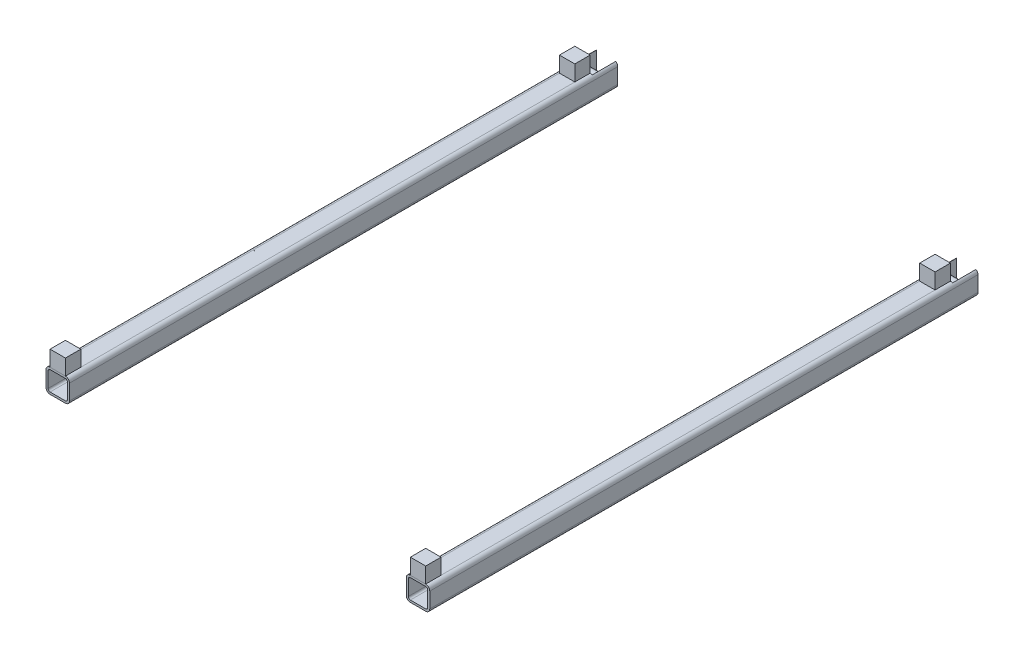
from build123d import *

# Parameters (mm, degrees)
SQUARE_TUBE_CONFIGURED_30_X_30_X_2_6_4_DEPTH = 700
SQUARE_TUBE_CONFIGURED_30_X_30_X_2_2_DEPTH   = 700
SKETCH113_W                                  = 24.8
SKETCH113_H                                  = 30
CUT_EXTRUDE1_DEPTH                           = 429.281449517
BOSS_EXTRUDE1_REACH                          = 582.279
SKETCH114_R                                  = 5
SKETCH115_W                                  = 24.8
SKETCH115_H                                  = 30
CUT_EXTRUDE2_DEPTH                           = 429.281449517
SKETCH117_W                                  = 19.6
SKETCH117_H                                  = 19.6
BOSS_EXTRUDE2_DEPTH                          = 20
SKETCH118_W                                  = 19.6
SKETCH118_H                                  = 19.6
BOSS_EXTRUDE3_DEPTH                          = 20


with BuildPart() as part:
    # Sketch116 → Square tube - configured 30 X 30 X 2.6(4) (new body)
    with BuildSketch(Plane(origin=(-230, 0, -350), x_dir=(0, 1, 0), z_dir=(0, 0, 1))):
        with BuildLine():
            Line((-9.8, -15), (9.8, -15))
            ThreePointArc((9.8, -15), (13.476955262, -13.476955262), (15, -9.8))
            Line((15, -9.8), (15, 9.8))
            ThreePointArc((15, 9.8), (13.476955262, 13.476955262), (9.8, 15))
            Line((9.8, 15), (-9.8, 15))
            ThreePointArc((-9.8, 15), (-13.476955262, 13.476955262), (-15, 9.8))
            Line((-15, 9.8), (-15, -9.8))
            ThreePointArc((-15, -9.8), (-13.476955262, -13.476955262), (-9.8, -15))
        make_face()
        with BuildLine():
            Line((-9.8, -12.4), (9.8, -12.4))
            ThreePointArc((9.8, -12.4), (11.638477631, -11.638477631), (12.4, -9.8))
            Line((12.4, -9.8), (12.4, 9.8))
            ThreePointArc((12.4, 9.8), (11.638477631, 11.638477631), (9.8, 12.4))
            Line((9.8, 12.4), (-9.8, 12.4))
            ThreePointArc((-9.8, 12.4), (-11.638477631, 11.638477631), (-12.4, 9.8))
            Line((-12.4, 9.8), (-12.4, -9.8))
            ThreePointArc((-12.4, -9.8), (-11.638477631, -11.638477631), (-9.8, -12.4))
        make_face(mode=Mode.SUBTRACT)
    extrude(amount=SQUARE_TUBE_CONFIGURED_30_X_30_X_2_6_4_DEPTH)

    # Sketch113 → Cut-Extrude1 (cut, through all)
    with BuildSketch(Plane(origin=(0, 15, 0), x_dir=(1, 0, 0), z_dir=(0, 1, 0))):
        with Locations((-230, 335)):
            Rectangle(SKETCH113_W, SKETCH113_H)
    extrude(amount=-CUT_EXTRUDE1_DEPTH, mode=Mode.SUBTRACT)


with BuildPart() as body_2:
    # Sketch116 on segment 2 (carried to segment 2) → Square tube - configured 30 X 30 X 2 2 (new body)
    with BuildSketch(Plane(origin=(230, 0, -350), x_dir=(0, 1, 0), z_dir=(0, 0, 1))):
        with BuildLine():
            Line((-9.8, -15), (9.8, -15))
            ThreePointArc((9.8, -15), (13.476955262, -13.476955262), (15, -9.8))
            Line((15, -9.8), (15, 9.8))
            ThreePointArc((15, 9.8), (13.476955262, 13.476955262), (9.8, 15))
            Line((9.8, 15), (-9.8, 15))
            ThreePointArc((-9.8, 15), (-13.476955262, 13.476955262), (-15, 9.8))
            Line((-15, 9.8), (-15, -9.8))
            ThreePointArc((-15, -9.8), (-13.476955262, -13.476955262), (-9.8, -15))
        make_face()
        with BuildLine():
            Line((-9.8, -12.4), (9.8, -12.4))
            ThreePointArc((9.8, -12.4), (11.638477631, -11.638477631), (12.4, -9.8))
            Line((12.4, -9.8), (12.4, 9.8))
            ThreePointArc((12.4, 9.8), (11.638477631, 11.638477631), (9.8, 12.4))
            Line((9.8, 12.4), (-9.8, 12.4))
            ThreePointArc((-9.8, 12.4), (-11.638477631, 11.638477631), (-12.4, 9.8))
            Line((-12.4, 9.8), (-12.4, -9.8))
            ThreePointArc((-12.4, -9.8), (-11.638477631, -11.638477631), (-9.8, -12.4))
        make_face(mode=Mode.SUBTRACT)
    extrude(amount=SQUARE_TUBE_CONFIGURED_30_X_30_X_2_2_DEPTH)

    # Sketch115 → Cut-Extrude2 (cut, through all)
    with BuildSketch(Plane(origin=(0, 15, 0), x_dir=(1, 0, 0), z_dir=(0, 1, 0))):
        with Locations((230, 335)):
            Rectangle(SKETCH115_W, SKETCH115_H)
    extrude(amount=-CUT_EXTRUDE2_DEPTH, mode=Mode.SUBTRACT)


with BuildPart() as body_3:

    # Sketch114 → Boss-Extrude1 (new, up to next)
    with BuildSketch(Plane.ZY.offset(217.6), mode=Mode.PRIVATE) as boss_extrude1_sk1:
        with Locations(Location((-335, 0, 0), (0, 0, 90))):
            Circle(SKETCH114_R)
    boss_extrude1_tool1 = extrude(boss_extrude1_sk1.sketch, amount=BOSS_EXTRUDE1_REACH, mode=Mode.PRIVATE) - part.part
    add(boss_extrude1_tool1.solids().sort_by_distance((-217.6, 0, -335))[0])


with BuildPart() as body_4:
    # Mirror8: mirrored copy
    add(body_3.part.mirror(Plane(origin=(0, 0, 0), x_dir=(0, 0, 1), z_dir=(1, 0, 0))))


with BuildPart() as body_5:
    # Sketch117 → Boss-Extrude2 (new body)
    with BuildSketch(Plane(origin=(0, 15, 0), x_dir=(1, 0, 0), z_dir=(0, 1, 0))):
        with Locations((-230, -340.2)):
            Rectangle(SKETCH117_W, SKETCH117_H)
    extrude(amount=BOSS_EXTRUDE2_DEPTH)


with BuildPart() as body_6:
    # Mirror9: mirrored copy
    add(body_5.part.mirror(Plane(origin=(0, 0, 0), x_dir=(0, 0, 1), z_dir=(1, 0, 0))))


with BuildPart() as body_7:
    # Sketch118 → Boss-Extrude3 (new body)
    with BuildSketch(Plane(origin=(0, 15, 0), x_dir=(1, 0, 0), z_dir=(0, 1, 0))):
        with Locations((-230, 310.2)):
            Rectangle(SKETCH118_W, SKETCH118_H)
    extrude(amount=BOSS_EXTRUDE3_DEPTH)


with BuildPart() as body_8:
    # Mirror10: mirrored copy
    add(body_7.part.mirror(Plane(origin=(0, 0, 0), x_dir=(0, 0, 1), z_dir=(1, 0, 0))))


solid = Compound([part.part, body_2.part, body_3.part, body_4.part, body_5.part, body_6.part, body_7.part, body_8.part])
